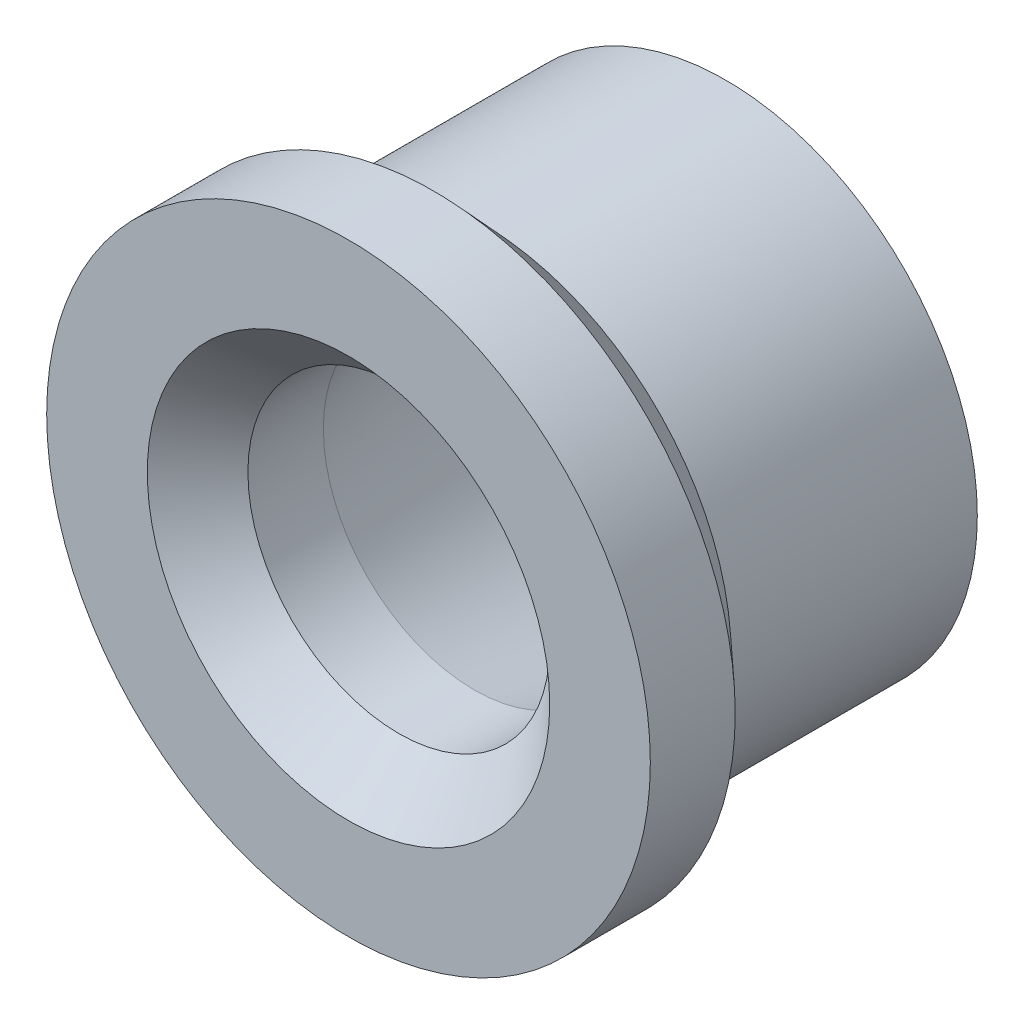
from build123d import *

# Parameters (mm, degrees)
CROQUIS2_R            = 3
CORTAR_EXTRUIR1_DEPTH = 10
CHAFL_N1_SIZE         = 1


with BuildPart() as part:
    # Croquis1 → Revolución1 (revolve)
    with BuildSketch(Plane(origin=(0, 0, 0), x_dir=(1, 0, 0), z_dir=(0, 1, 0))):
        Polygon((-3, -1.25), (-4, 3.75), (-5, 3.75), (-5, -1.140510949), (-6, -2.062248439), (-6, -3.75), (0, -3.75), (0, -1.25), align=None)
    revolve(axis=Axis((0, 0, -3.75), (0, 0, 1)))

    # Croquis2 → Cortar-Extruir1 (cut)
    with BuildSketch(Plane.XY.offset(3.75)):
        Circle(CROQUIS2_R)
    extrude(amount=-CORTAR_EXTRUIR1_DEPTH, mode=Mode.SUBTRACT)

    # Chaflán1
    chafl_n1_edges = [part.edges().sort_by_distance(p)[0] for p in [
        (-3, 0, 3.75),
    ]]
    chamfer(chafl_n1_edges, length=CHAFL_N1_SIZE)


solid = part.part
